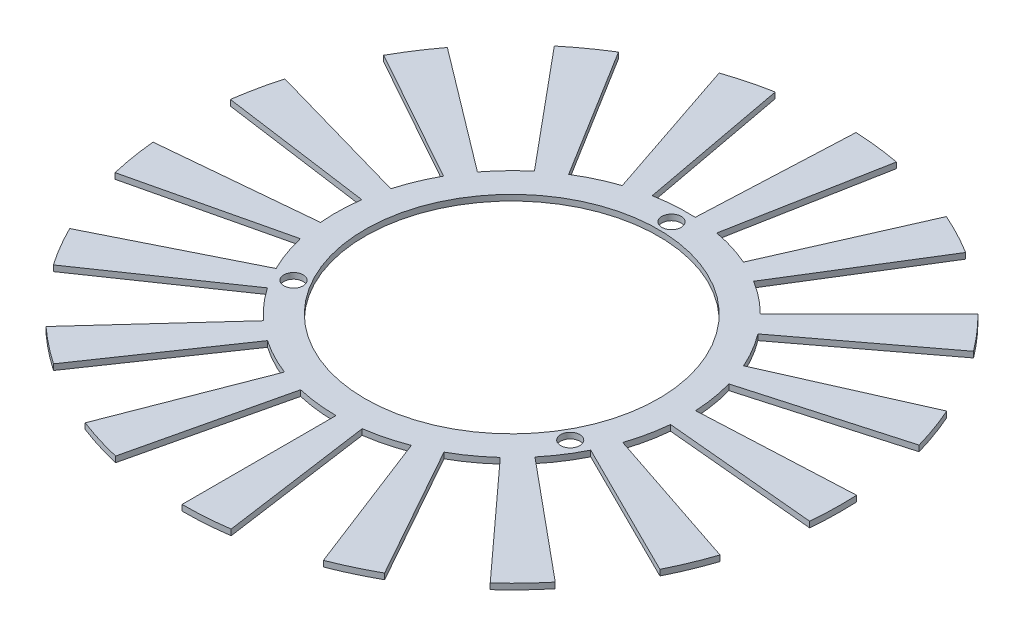
from build123d import *

# Parameters (mm, degrees)
SKETCH1_R           = 30.25
SKETCH1_R_2         = 25.25
EXTRUDE_THIN1_DEPTH = 1
SKETCH2_R           = 1.65
CUT_EXTRUDE3_DEPTH  = 10
BOSS_EXTRUDE1_DEPTH = 1


with BuildPart() as part:
    # Sketch1 → Extrude-Thin1 (new body)
    with BuildSketch(Plane(origin=(0, 0, 0), x_dir=(1, 0, 0), z_dir=(0, 1, 0))):
        Circle(SKETCH1_R)
        Circle(SKETCH1_R_2, mode=Mode.SUBTRACT)
    extrude(amount=-EXTRUDE_THIN1_DEPTH)

    # Sketch2 → Cut-Extrude3 (cut)
    with BuildSketch(Plane(origin=(0, 0, 0), x_dir=(1, 0, 0), z_dir=(0, 1, 0))):
        with Locations((0, 27.5)):
            Circle(SKETCH2_R)
        with Locations((23.815698604, -13.75)):
            Circle(SKETCH2_R)
        with Locations((-23.815698604, -13.75)):
            Circle(SKETCH2_R)
    extrude(amount=-CUT_EXTRUDE3_DEPTH, mode=Mode.SUBTRACT)

    # Sketch5 → Boss-Extrude1 (add)
    with BuildSketch(Plane.XZ.offset(1)):
        with BuildLine():
            Line((0, 56.75), (0, 30.25))
            ThreePointArc((0, 30.25), (2.110133331, 30.17631252), (4.209986304, 29.955609079))
            Line((4.209986304, 29.955609079), (7.898073479, 56.197712901))
            ThreePointArc((7.898073479, 56.197712901), (3.958679885, 56.611759852), (0, 56.75))
        make_face()
        with BuildLine():
            Line((20.500464556, 52.917799019), (10.927560402, 28.207284939))
            ThreePointArc((10.927560402, 28.207284939), (12.868582146, 27.376305331), (14.74690945, 26.411951114))
            Line((14.74690945, 26.411951114), (27.66568963, 49.549693413))
            ThreePointArc((27.66568963, 49.549693413), (24.141885513, 51.358853802), (20.500464556, 52.917799019))
        make_face()
        with BuildLine():
            Line((38.232227777, 41.938756052), (20.37929322, 22.355019746))
            ThreePointArc((20.37929322, 22.355019746), (21.889057634, 20.878976409), (23.29218076, 19.301212798))
            Line((23.29218076, 19.301212798), (43.696901095, 36.209713265))
            ThreePointArc((43.696901095, 36.209713265), (41.064595727, 39.169649957), (38.232227777, 41.938756052))
        make_face()
        with BuildLine():
            Line((50.800516784, 25.29565169), (27.078689563, 13.483585262))
            ThreePointArc((27.078689563, 13.483585262), (27.953294598, 11.561826029), (28.691713991, 9.583738741))
            Line((28.691713991, 9.583738741), (53.826603934, 17.979410696))
            ThreePointArc((53.826603934, 17.979410696), (52.441304742, 21.690367839), (50.800516784, 25.29565169))
        make_face()
        with BuildLine():
            Line((56.507914505, 5.2362294), (30.120958833, 2.791117874))
            ThreePointArc((30.120958833, 2.791117874), (30.242284232, 0.683186977), (30.216272262, -1.428072338))
            Line((30.216272262, -1.428072338), (56.686725648, -2.679110915))
            ThreePointArc((56.686725648, -2.679110915), (56.735524964, 1.281681353), (56.507914505, 5.2362294))
        make_face()
        with BuildLine():
            Line((54.58360525, -15.530374687), (29.095225706, -8.27830545))
            ThreePointArc((29.095225706, -8.27830545), (28.446885802, -10.287720262), (27.659955529, -12.247014335))
            Line((27.659955529, -12.247014335), (51.890990952, -22.975803752))
            ThreePointArc((51.890990952, -22.975803752), (53.367298157, -19.300103301), (54.58360525, -15.530374687))
        make_face()
        with BuildLine():
            Line((45.287477648, -34.199515615), (24.140021125, -18.22969775))
            ThreePointArc((24.140021125, -18.22969775), (22.809577815, -19.869213873), (21.368008534, -21.411929182))
            Line((21.368008534, -21.411929182), (40.087090389, -40.169486978))
            ThreePointArc((40.087090389, -40.169486978), (42.791522016, -37.275302059), (45.287477648, -34.199515615))
        make_face()
        with BuildLine():
            Line((29.875025243, -48.249822453), (15.924572927, -25.719068356))
            ThreePointArc((15.924572927, -25.719068356), (14.091709951, -26.767260051), (12.190193581, -27.685044346))
            Line((12.190193581, -27.685044346), (22.86920614, -51.938058402))
            ThreePointArc((22.86920614, -51.938058402), (26.43651371, -50.216264724), (29.875025243, -48.249822453))
        make_face()
        with BuildLine():
            Line((10.427785136, -55.783723407), (5.558422914, -29.734936265))
            ThreePointArc((5.558422914, -29.734936265), (3.470678574, -30.050239437), (1.366025437, -30.219140863))
            Line((1.366025437, -30.219140863), (2.562708878, -56.692107239))
            ThreePointArc((2.562708878, -56.692107239), (6.511107738, -56.375242581), (10.427785136, -55.783723407))
        make_face()
        with BuildLine():
            Line((-10.427785136, -55.783723407), (-5.558422914, -29.734936265))
            ThreePointArc((-5.558422914, -29.734936265), (-7.619087176, -29.274767473), (-9.642632011, -28.671974956))
            Line((-9.642632011, -28.671974956), (-18.089896418, -53.789572852))
            ThreePointArc((-18.089896418, -53.789572852), (-14.293659413, -54.92043154), (-10.427785136, -55.783723407))
        make_face()
        with BuildLine():
            Line((-29.875025243, -48.249822453), (-15.924572927, -25.719068356))
            ThreePointArc((-15.924572927, -25.719068356), (-17.679852984, -24.545575945), (-19.348998575, -23.252499955))
            Line((-19.348998575, -23.252499955), (-36.299360963, -43.622458593))
            ThreePointArc((-36.299360963, -43.622458593), (-33.167988656, -46.048311896), (-29.875025243, -48.249822453))
        make_face()
        with BuildLine():
            Line((-45.287477648, -34.199515615), (-24.140021125, -18.22969775))
            ThreePointArc((-24.140021125, -18.22969775), (-25.35285668, -16.501368373), (-26.442175665, -14.692645988))
            Line((-26.442175665, -14.692645988), (-49.606395668, -27.563889581))
            ThreePointArc((-49.606395668, -27.563889581), (-47.562797242, -30.957112568), (-45.287477648, -34.199515615))
        make_face()
        with BuildLine():
            Line((-54.58360525, -15.530374687), (-29.095225706, -8.27830545))
            ThreePointArc((-29.095225706, -8.27830545), (-29.601816595, -6.228559566), (-29.96419041, -4.148468765))
            Line((-29.96419041, -4.148468765), (-56.21381176, -7.782664543))
            ThreePointArc((-56.21381176, -7.782664543), (-55.533986505, -11.684983648), (-54.58360525, -15.530374687))
        make_face()
        with BuildLine():
            Line((-56.507914505, 5.2362294), (-30.120958833, 2.791117874))
            ThreePointArc((-30.120958833, 2.791117874), (-29.85288715, 4.885450725), (-29.439375202, 6.955982151))
            Line((-29.439375202, 6.955982151), (-55.229241082, 13.049652465))
            ThreePointArc((-55.229241082, 13.049652465), (-56.005003166, 9.165267062), (-56.507914505, 5.2362294))
        make_face()
        with BuildLine():
            Line((-50.800516784, 25.29565169), (-27.078689563, 13.483585262))
            ThreePointArc((-27.078689563, 13.483585262), (-26.072159875, 15.339653824), (-24.938609245, 17.120989134))
            Line((-24.938609245, 17.120989134), (-46.785655361, 32.119541598))
            ThreePointArc((-46.785655361, 32.119541598), (-48.912233816, 28.777697669), (-50.800516784, 25.29565169))
        make_face()
        with BuildLine():
            Line((-38.232227777, 41.938756052), (-20.37929322, 22.355019746))
            ThreePointArc((-20.37929322, 22.355019746), (-18.770242938, 23.722151674), (-17.06974592, 24.973711663))
            Line((-17.06974592, 24.973711663), (-32.023407634, 46.851508658))
            ThreePointArc((-32.023407634, 46.851508658), (-35.213596256, 44.503540743), (-38.232227777, 41.938756052))
        make_face()
        with BuildLine():
            Line((-20.500464556, 52.917799019), (-10.927560402, 28.207284939))
            ThreePointArc((-10.927560402, 28.207284939), (-8.933300683, 28.900841491), (-6.895518821, 29.453596049))
            Line((-6.895518821, 29.453596049), (-12.936221259, 55.25591986))
            ThreePointArc((-12.936221259, 55.25591986), (-16.759167397, 54.218934037), (-20.500464556, 52.917799019))
        make_face()
    extrude(amount=-BOSS_EXTRUDE1_DEPTH)


solid = part.part
